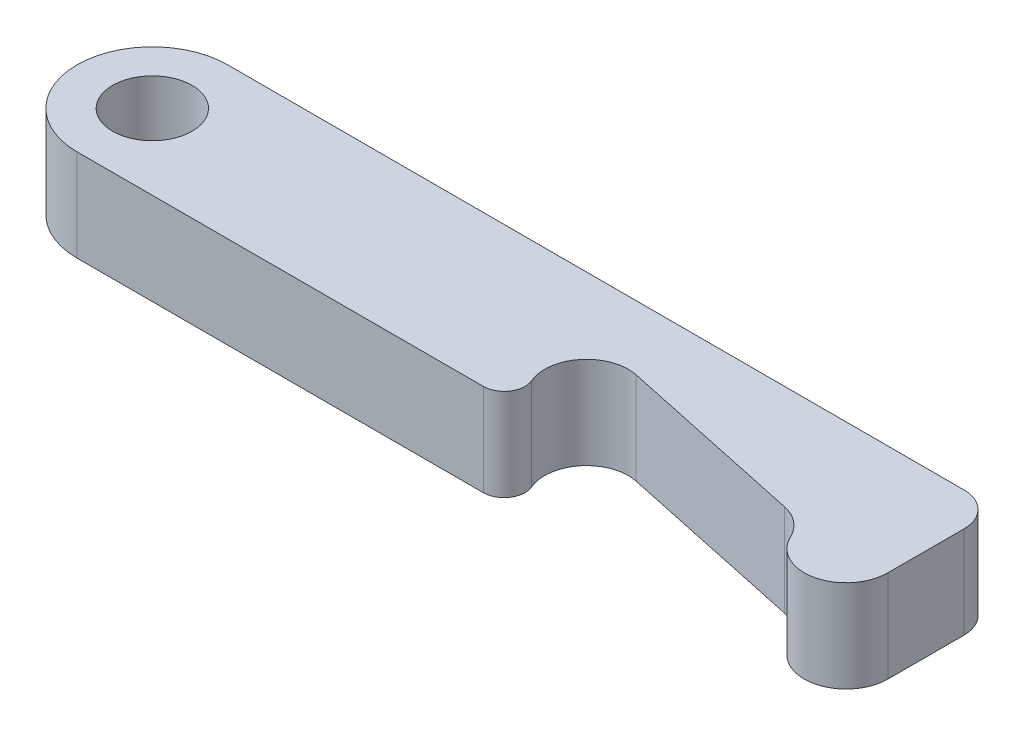
from build123d import *

# Parameters (mm, degrees)
SKETCH1_R           = 4.75
BOSS_EXTRUDE1_DEPTH = 11


with BuildPart() as part:
    # Sketch1 → Boss-Extrude1 (new body)
    with BuildSketch(Plane(origin=(0, 0, 0), x_dir=(1, 0, 0), z_dir=(0, 1, 0))):
        with BuildLine():
            Line((0, 9), (88, 9))
            ThreePointArc((88, 9), (90.828427125, 7.828427125), (92, 5))
            Line((92, 5), (92, -4.118760913))
            ThreePointArc((92, -4.118760913), (88.083284346, -9), (82.46940199, -6.233868869))
            ThreePointArc((82.46940199, -6.233868869), (81.050506295, -4.43524348), (78.978362433, -3.458238822))
            Line((78.978362433, -3.458238822), (56.478362433, 1.324283815))
            ThreePointArc((56.478362433, 1.324283815), (51.57997572, -0.38691893), (50.837146839, -5.522151396))
            ThreePointArc((50.837146839, -5.522151396), (50.621338834, -7.879380022), (48.53631827, -9))
            Line((48.53631827, -9), (0, -9))
            ThreePointArc((0, -9), (-9, 0), (0, 9))
        make_face()
        Circle(SKETCH1_R, mode=Mode.SUBTRACT)
    extrude(amount=BOSS_EXTRUDE1_DEPTH)


solid = part.part
